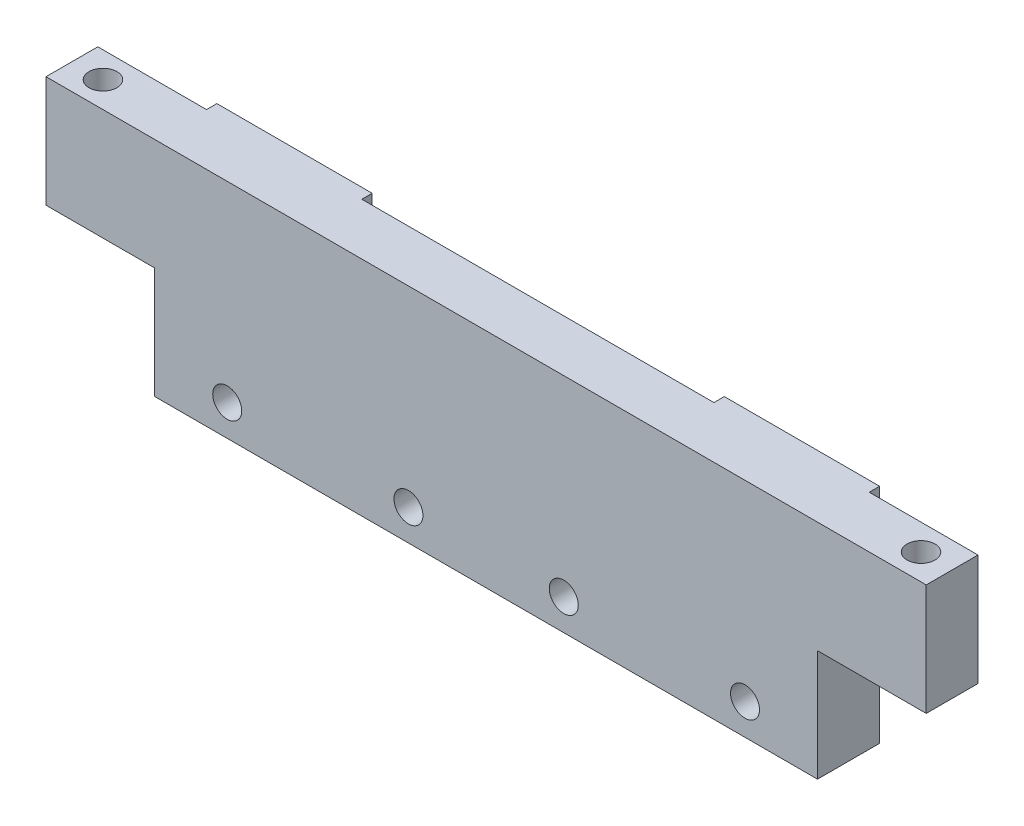
from build123d import *

# Parameters (mm, degrees)
SKETCH1_R               = 1.35
BOSS_EXTRUDE1_DEPTH     = 21.5
SKETCH2_R               = 1.4
CUT_EXTRUDE1_DEPTH      = 21.5
SKETCH3_W               = 10.5
SKETCH3_H               = 10.75
CUT_EXTRUDE2_DEPTH      = 2
CUT_EXTRUDE2_DEPTH_BACK = 6


with BuildPart() as part:
    # Sketch1 → Boss-Extrude1 (new body)
    with BuildSketch(Plane(origin=(0, 0, 0), x_dir=(1, 0, 0), z_dir=(0, 1, 0))):
        Polygon((42.5, -2.5), (-42.5, -2.5), (-42.5, 2.5), (-32, 2.5), (-32, 3.5), (-17, 3.5), (-17, 2.5), (17, 2.5), (17, 3.5), (32, 3.5), (32, 2.5), (42.5, 2.5), align=None)
        with Locations((-39.5, 0)):
            Circle(SKETCH1_R, mode=Mode.SUBTRACT)
        with Locations((39.5, 0)):
            Circle(SKETCH1_R, mode=Mode.SUBTRACT)
    extrude(amount=BOSS_EXTRUDE1_DEPTH)

    # Sketch2 → Cut-Extrude1 (cut)
    with BuildSketch(Plane(origin=(0, 0, 2.5), x_dir=(-1, 0, 0), z_dir=(0, 0, -1))):
        with Locations((-7.5, 3)):
            Circle(SKETCH2_R)
        with Locations((7.5, 3)):
            Circle(SKETCH2_R)
        with Locations((-25, 3)):
            Circle(SKETCH2_R)
        with Locations((25, 3)):
            Circle(SKETCH2_R)
    extrude(amount=CUT_EXTRUDE1_DEPTH, mode=Mode.SUBTRACT)

    # Sketch3 → Cut-Extrude2 (cut, two sides)
    with BuildSketch(Plane(origin=(0, 0, -2.5), x_dir=(-1, 0, 0), z_dir=(0, 0, -1))) as cut_extrude2_sk:
        with Locations((-37.25, 5.375)):
            Rectangle(SKETCH3_W, SKETCH3_H)
        with Locations((37.25, 5.375)):
            Rectangle(SKETCH3_W, SKETCH3_H)
    extrude(amount=CUT_EXTRUDE2_DEPTH, mode=Mode.SUBTRACT)
    extrude(cut_extrude2_sk.sketch, amount=-CUT_EXTRUDE2_DEPTH_BACK, mode=Mode.SUBTRACT)


solid = part.part
